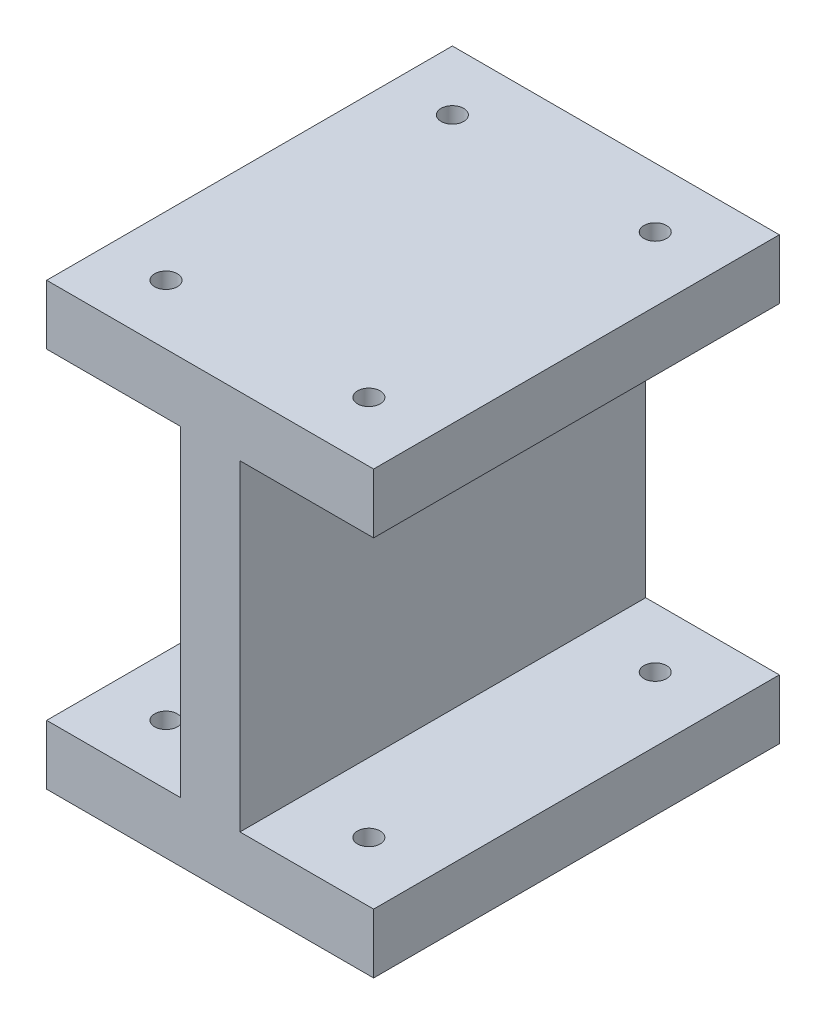
from build123d import *

# Parameters (mm, degrees)
SKETCH1_W           = 34.798
SKETCH1_H           = 46.9138
BOSS_EXTRUDE1_DEPTH = 43.18
SKETCH2_W           = 14.224
SKETCH2_H           = 34.2138
CUT_EXTRUDE1_DEPTH  = 43.18
SKETCH3_R           = 1.2065
CUT_EXTRUDE2_DEPTH  = 47.9138


with BuildPart() as part:
    # Sketch1 → Boss-Extrude1 (new body)
    with BuildSketch(Plane.XY):
        with Locations((17.399, 23.4569)):
            Rectangle(SKETCH1_W, SKETCH1_H)
    extrude(amount=-BOSS_EXTRUDE1_DEPTH)

    # Sketch2 → Cut-Extrude1 (cut)
    with BuildSketch(Plane.XY):
        with Locations((7.112, 23.4569)):
            Rectangle(SKETCH2_W, SKETCH2_H)
        with Locations((27.686, 23.4569)):
            Rectangle(SKETCH2_W, SKETCH2_H)
    extrude(amount=-CUT_EXTRUDE1_DEPTH, mode=Mode.SUBTRACT)

    # Sketch3 → Cut-Extrude2 (cut, through all)
    with BuildSketch(Plane(origin=(0, 46.9138, 0), x_dir=(1, 0, 0), z_dir=(0, 1, 0))):
        with Locations((6.35, 6.35)):
            Circle(SKETCH3_R)
        with Locations((27.94, 6.35)):
            Circle(SKETCH3_R)
        with Locations((6.35, 36.83)):
            Circle(SKETCH3_R)
        with Locations((27.94, 36.83)):
            Circle(SKETCH3_R)
    extrude(amount=-CUT_EXTRUDE2_DEPTH, mode=Mode.SUBTRACT)


solid = part.part
